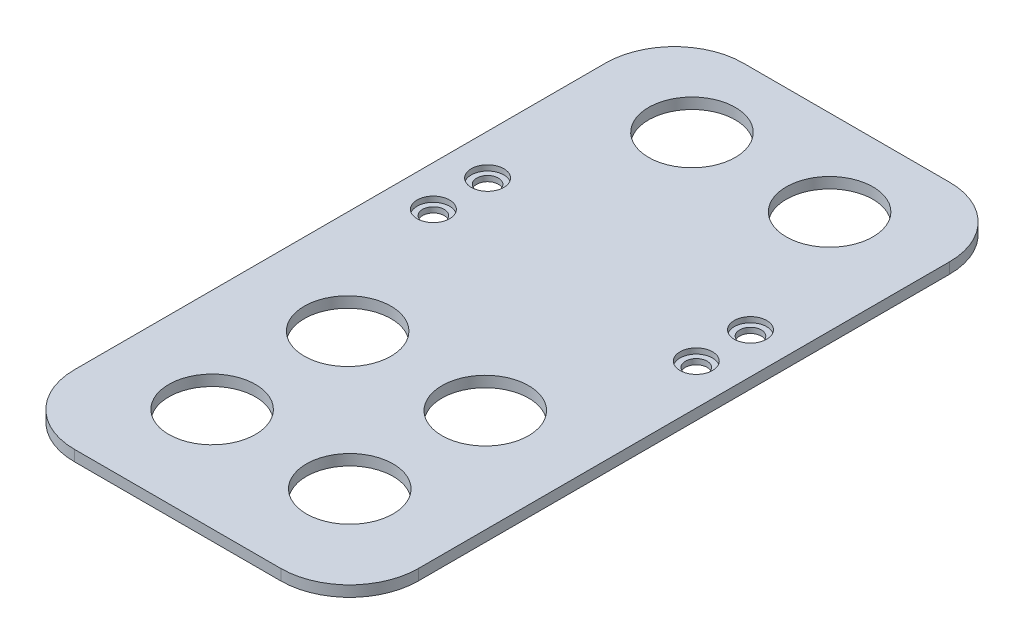
from build123d import *

# Parameters (mm, degrees)
SKETCH1_R           = 8
SKETCH1_R_2         = 2
BOSS_EXTRUDE1_DEPTH = 2
SKETCH2_R           = 3
CUT_EXTRUDE1_DEPTH  = 1


with BuildPart() as part:
    # Sketch1 → Boss-Extrude1 (new body)
    with BuildSketch(Plane(origin=(0, 0, 0), x_dir=(1, 0, 0), z_dir=(0, 1, 0))):
        with BuildLine():
            Line((19.05, -61.72), (-19.05, -61.72))
            ThreePointArc((-19.05, -61.72), (-28.030256121, -58.000256121), (-31.75, -49.02))
            Line((-31.75, -49.02), (-31.75, 49.02))
            ThreePointArc((-31.75, 49.02), (-28.030256121, 58.000256121), (-19.05, 61.72))
            Line((-19.05, 61.72), (19.05, 61.72))
            ThreePointArc((19.05, 61.72), (28.030256121, 58.000256121), (31.75, 49.02))
            Line((31.75, 49.02), (31.75, -49.02))
            ThreePointArc((31.75, -49.02), (28.030256121, -58.000256121), (19.05, -61.72))
        make_face()
        with Locations((-12.7, 45.91)):
            Circle(SKETCH1_R, mode=Mode.SUBTRACT)
        with Locations((12.7, 45.91)):
            Circle(SKETCH1_R, mode=Mode.SUBTRACT)
        with Locations((-12.7, -42.64)):
            Circle(SKETCH1_R, mode=Mode.SUBTRACT)
        with Locations((12.7, -42.64)):
            Circle(SKETCH1_R, mode=Mode.SUBTRACT)
        with Locations((12.7, -17.63)):
            Circle(SKETCH1_R, mode=Mode.SUBTRACT)
        with Locations((-12.7, -17.63)):
            Circle(SKETCH1_R, mode=Mode.SUBTRACT)
        with Locations((-24.26, 19.75)):
            Circle(SKETCH1_R_2, mode=Mode.SUBTRACT)
        with Locations((-24.26, 9.75)):
            Circle(SKETCH1_R_2, mode=Mode.SUBTRACT)
        with Locations((24.26, 19.75)):
            Circle(SKETCH1_R_2, mode=Mode.SUBTRACT)
        with Locations((24.26, 9.75)):
            Circle(SKETCH1_R_2, mode=Mode.SUBTRACT)
    extrude(amount=BOSS_EXTRUDE1_DEPTH)

    # Sketch2 → Cut-Extrude1 (cut)
    with BuildSketch(Plane(origin=(0, 2, 0), x_dir=(1, 0, 0), z_dir=(0, 1, 0))):
        with Locations((-24.26, 19.75)):
            Circle(SKETCH2_R)
        with Locations((-24.26, 9.75)):
            Circle(SKETCH2_R)
        with Locations((24.26, 19.75)):
            Circle(SKETCH2_R)
        with Locations((24.26, 9.75)):
            Circle(SKETCH2_R)
    extrude(amount=-CUT_EXTRUDE1_DEPTH, mode=Mode.SUBTRACT)


solid = part.part
